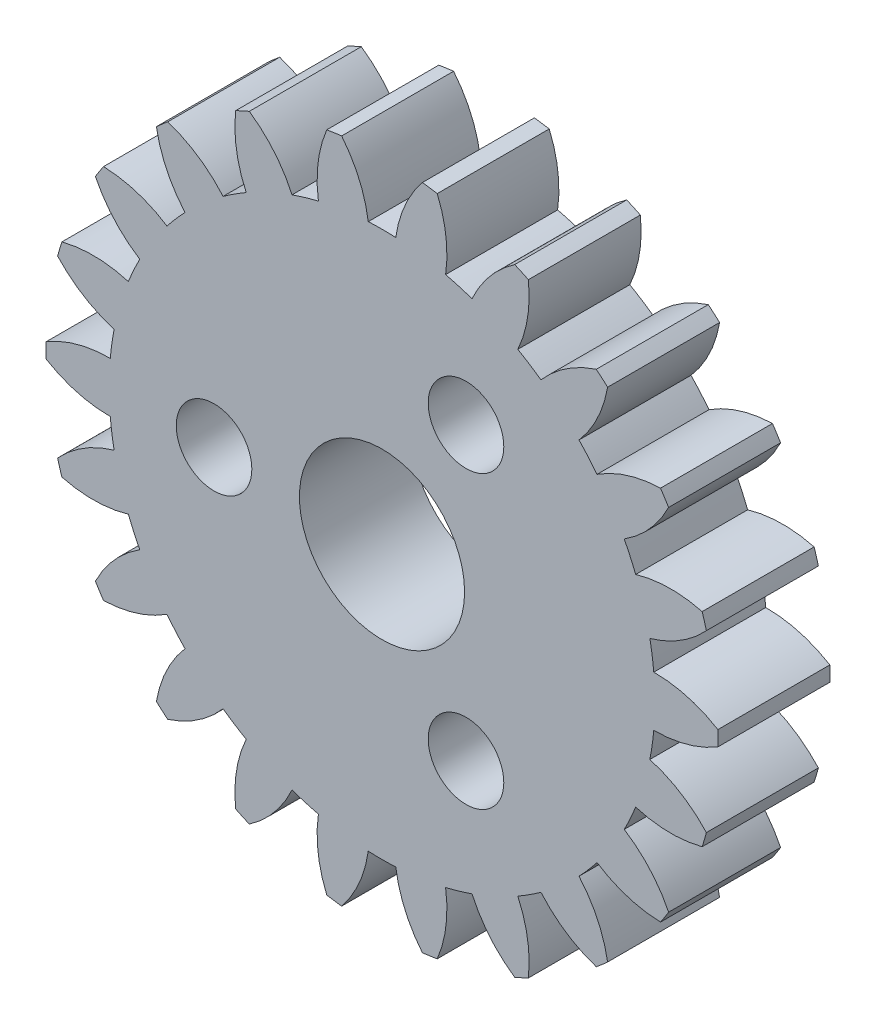
from build123d import *

# Parameters (mm, degrees)
MODEL_R             = 2.5
BOSS_EXTRUDE1_DEPTH = 4
SKETCH2_R           = 2.95
CUT_EXTRUDE1_DEPTH  = 4
SKETCH3_R           = 1.35
CUT_EXTRUDE2_DEPTH  = 4
CIRPATTERN1_COUNT   = 3


with BuildPart() as part:
    # Model → Boss-Extrude1 (new body)
    with BuildSketch(Plane.XY):
        with BuildLine():
            ThreePointArc((-11.997000624, 0.268283487), (-12, 0), (-11.997000624, -0.268283487))
            ThreePointArc((-11.997000624, -0.268283487), (-10.895606779, -0.741380557), (-9.707399683, -0.89966238))
            ThreePointArc((-9.707399683, -0.89966238), (-9.649769237, -1.387427358), (-9.56764597, -1.8716708))
            ThreePointArc((-9.56764597, -1.8716708), (-10.663129188, -2.358297721), (-11.586621996, -3.122529539))
            ThreePointArc((-11.586621996, -3.122529539), (-11.513915683, -3.380790682), (-11.43545361, -3.637361781))
            ThreePointArc((-11.43545361, -3.637361781), (-10.245387108, -3.780996591), (-9.060717605, -3.598110265))
            ThreePointArc((-9.060717605, -3.598110265), (-8.868002323, -4.049880962), (-8.652778483, -4.491372344))
            ThreePointArc((-8.652778483, -4.491372344), (-9.566788286, -5.266920743), (-10.237564162, -6.260373793))
            ThreePointArc((-10.237564162, -6.260373793), (-10.095042394, -6.487689809), (-9.947474154, -6.711762656))
            ThreePointArc((-9.947474154, -6.711762656), (-8.765147105, -6.514298768), (-7.679990073, -6.005060656))
            ThreePointArc((-7.679990073, -6.005060656), (-7.3678026, -6.384237295), (-7.036914342, -6.747209612))
            ThreePointArc((-7.036914342, -6.747209612), (-7.695403093, -7.74884917), (-8.059119765, -8.891039794))
            ThreePointArc((-8.059119765, -8.891039794), (-7.858328807, -9.068994892), (-7.653609502, -9.242416436))
            ThreePointArc((-7.653609502, -9.242416436), (-6.574807012, -8.719851201), (-5.67707542, -7.925516745))
            ThreePointArc((-5.67707542, -7.925516745), (-5.270707329, -8.201380692), (-4.850961252, -8.456428084))
            ThreePointArc((-4.850961252, -8.456428084), (-5.200582107, -9.603011921), (-5.227773414, -10.801406627))
            ThreePointArc((-5.227773414, -10.801406627), (-4.984980156, -10.915583944), (-4.739694926, -11.024304604))
            ThreePointArc((-4.739694926, -11.024304604), (-3.851815156, -10.218973149), (-3.214237879, -9.203894603))
            ThreePointArc((-3.214237879, -9.203894603), (-2.746610697, -9.354097), (-2.27201213, -9.480557045))
            ThreePointArc((-2.27201213, -9.480557045), (-2.284440889, -10.679195758), (-1.972903952, -11.836707735))
            ThreePointArc((-1.972903952, -11.836707735), (-1.707778059, -11.877857303), (-1.441798455, -11.913069177))
            ThreePointArc((-1.441798455, -11.913069177), (-0.816772145, -10.890214666), (-0.491001901, -9.736627657))
            ThreePointArc((-0.491001901, -9.736627657), (0, -9.749), (0.491001901, -9.736627657))
            ThreePointArc((0.491001901, -9.736627657), (0.816772145, -10.890214666), (1.441798455, -11.913069177))
            ThreePointArc((1.441798455, -11.913069177), (1.707778059, -11.877857303), (1.972903952, -11.836707735))
            ThreePointArc((1.972903952, -11.836707735), (2.284440889, -10.679195758), (2.27201213, -9.480557045))
            ThreePointArc((2.27201213, -9.480557045), (2.746610697, -9.354097), (3.214237879, -9.203894603))
            ThreePointArc((3.214237879, -9.203894603), (3.851815156, -10.218973149), (4.739694926, -11.024304604))
            ThreePointArc((4.739694926, -11.024304604), (4.984980156, -10.915583944), (5.227773414, -10.801406627))
            ThreePointArc((5.227773414, -10.801406627), (5.200582107, -9.603011921), (4.850961252, -8.456428084))
            ThreePointArc((4.850961252, -8.456428084), (5.270707329, -8.201380692), (5.67707542, -7.925516745))
            ThreePointArc((5.67707542, -7.925516745), (6.574807012, -8.719851201), (7.653609502, -9.242416436))
            ThreePointArc((7.653609502, -9.242416436), (7.858328807, -9.068994892), (8.059119765, -8.891039794))
            ThreePointArc((8.059119765, -8.891039794), (7.695403093, -7.74884917), (7.036914342, -6.747209612))
            ThreePointArc((7.036914342, -6.747209612), (7.3678026, -6.384237295), (7.679990073, -6.005060656))
            ThreePointArc((7.679990073, -6.005060656), (8.765147105, -6.514298768), (9.947474154, -6.711762656))
            ThreePointArc((9.947474154, -6.711762656), (10.095042394, -6.487689809), (10.237564162, -6.260373793))
            ThreePointArc((10.237564162, -6.260373793), (9.566788286, -5.266920743), (8.652778482, -4.491372344))
            ThreePointArc((8.652778482, -4.491372344), (8.868002323, -4.049880962), (9.060717605, -3.598110265))
            ThreePointArc((9.060717605, -3.598110265), (10.245387108, -3.780996591), (11.43545361, -3.637361781))
            ThreePointArc((11.43545361, -3.637361781), (11.513915683, -3.380790682), (11.586621996, -3.122529539))
            ThreePointArc((11.586621996, -3.122529539), (10.663129188, -2.358297721), (9.56764597, -1.8716708))
            ThreePointArc((9.56764597, -1.8716708), (9.649769237, -1.387427358), (9.707399683, -0.89966238))
            ThreePointArc((9.707399683, -0.89966238), (10.895606779, -0.741380557), (11.997000624, -0.268283487))
            ThreePointArc((11.997000624, -0.268283487), (12, 0), (11.997000624, 0.268283487))
            ThreePointArc((11.997000624, 0.268283487), (10.895606779, 0.741380557), (9.707399683, 0.89966238))
            ThreePointArc((9.707399683, 0.89966238), (9.649769237, 1.387427358), (9.56764597, 1.8716708))
            ThreePointArc((9.56764597, 1.8716708), (10.663129188, 2.358297721), (11.586621996, 3.122529539))
            ThreePointArc((11.586621996, 3.122529539), (11.513915683, 3.380790682), (11.43545361, 3.637361781))
            ThreePointArc((11.43545361, 3.637361781), (10.245387108, 3.780996591), (9.060717605, 3.598110265))
            ThreePointArc((9.060717605, 3.598110265), (8.868002323, 4.049880962), (8.652778483, 4.491372344))
            ThreePointArc((8.652778483, 4.491372344), (9.566788286, 5.266920743), (10.237564162, 6.260373793))
            ThreePointArc((10.237564162, 6.260373793), (10.095042394, 6.487689809), (9.947474154, 6.711762656))
            ThreePointArc((9.947474154, 6.711762656), (8.765147105, 6.514298768), (7.679990073, 6.005060656))
            ThreePointArc((7.679990073, 6.005060656), (7.3678026, 6.384237295), (7.036914342, 6.747209612))
            ThreePointArc((7.036914342, 6.747209612), (7.695403093, 7.74884917), (8.059119765, 8.891039794))
            ThreePointArc((8.059119765, 8.891039794), (7.858328807, 9.068994892), (7.653609502, 9.242416436))
            ThreePointArc((7.653609502, 9.242416436), (6.574807012, 8.719851201), (5.67707542, 7.925516745))
            ThreePointArc((5.67707542, 7.925516745), (5.270707329, 8.201380692), (4.850961252, 8.456428084))
            ThreePointArc((4.850961252, 8.456428084), (5.200582107, 9.603011921), (5.227773414, 10.801406627))
            ThreePointArc((5.227773414, 10.801406627), (4.984980156, 10.915583944), (4.739694926, 11.024304604))
            ThreePointArc((4.739694926, 11.024304604), (3.851815156, 10.218973149), (3.214237879, 9.203894603))
            ThreePointArc((3.214237879, 9.203894603), (2.746610697, 9.354097), (2.27201213, 9.480557045))
            ThreePointArc((2.27201213, 9.480557045), (2.284440889, 10.679195758), (1.972903952, 11.836707735))
            ThreePointArc((1.972903952, 11.836707735), (1.707778059, 11.877857303), (1.441798455, 11.913069177))
            ThreePointArc((1.441798455, 11.913069177), (0.816772145, 10.890214666), (0.491001901, 9.736627657))
            ThreePointArc((0.491001901, 9.736627657), (0, 9.749), (-0.491001901, 9.736627657))
            ThreePointArc((-0.491001901, 9.736627657), (-0.816772145, 10.890214666), (-1.441798455, 11.913069177))
            ThreePointArc((-1.441798455, 11.913069177), (-1.707778059, 11.877857303), (-1.972903952, 11.836707735))
            ThreePointArc((-1.972903952, 11.836707735), (-2.284440889, 10.679195758), (-2.27201213, 9.480557045))
            ThreePointArc((-2.27201213, 9.480557045), (-2.746610697, 9.354097), (-3.214237879, 9.203894603))
            ThreePointArc((-3.214237879, 9.203894603), (-3.851815156, 10.218973149), (-4.739694926, 11.024304604))
            ThreePointArc((-4.739694926, 11.024304604), (-4.984980156, 10.915583944), (-5.227773414, 10.801406627))
            ThreePointArc((-5.227773414, 10.801406627), (-5.200582107, 9.603011921), (-4.850961252, 8.456428084))
            ThreePointArc((-4.850961252, 8.456428084), (-5.270707329, 8.201380692), (-5.67707542, 7.925516745))
            ThreePointArc((-5.67707542, 7.925516745), (-6.574807012, 8.719851201), (-7.653609502, 9.242416436))
            ThreePointArc((-7.653609502, 9.242416436), (-7.858328807, 9.068994892), (-8.059119765, 8.891039794))
            ThreePointArc((-8.059119765, 8.891039794), (-7.695403093, 7.74884917), (-7.036914342, 6.747209612))
            ThreePointArc((-7.036914342, 6.747209612), (-7.3678026, 6.384237295), (-7.679990073, 6.005060656))
            ThreePointArc((-7.679990073, 6.005060656), (-8.765147105, 6.514298768), (-9.947474154, 6.711762656))
            ThreePointArc((-9.947474154, 6.711762656), (-10.095042394, 6.487689809), (-10.237564162, 6.260373793))
            ThreePointArc((-10.237564162, 6.260373793), (-9.566788286, 5.266920743), (-8.652778482, 4.491372344))
            ThreePointArc((-8.652778482, 4.491372344), (-8.868002323, 4.049880962), (-9.060717605, 3.598110265))
            ThreePointArc((-9.060717605, 3.598110265), (-10.245387108, 3.780996591), (-11.43545361, 3.637361781))
            ThreePointArc((-11.43545361, 3.637361781), (-11.513915683, 3.380790682), (-11.586621996, 3.122529539))
            ThreePointArc((-11.586621996, 3.122529539), (-10.663129188, 2.358297721), (-9.56764597, 1.8716708))
            ThreePointArc((-9.56764597, 1.8716708), (-9.649769237, 1.387427358), (-9.707399683, 0.89966238))
            ThreePointArc((-9.707399683, 0.89966238), (-10.895606779, 0.741380557), (-11.997000624, 0.268283487))
        make_face()
        Circle(MODEL_R, mode=Mode.SUBTRACT)
    extrude(amount=BOSS_EXTRUDE1_DEPTH)

    # Sketch2 → Cut-Extrude1 (cut)
    with BuildSketch(Plane.XY.offset(4)):
        Circle(SKETCH2_R)
    extrude(amount=-CUT_EXTRUDE1_DEPTH, mode=Mode.SUBTRACT)

    # Sketch3 → Cut-Extrude2 (cut)
    with BuildSketch(Plane.XY.offset(4)):
        with Locations((-6, 0)):
            Circle(SKETCH3_R)
    cut_extrude2 = extrude(amount=-CUT_EXTRUDE2_DEPTH, mode=Mode.SUBTRACT)

    # CirPattern1: Cut-Extrude2 ×3 about axis
    cirpattern1_axis = Axis((0, 0, 0), (0, 0, 1))
    for i in range(1, CIRPATTERN1_COUNT):
        add(cut_extrude2.rotate(cirpattern1_axis, i * 360 / CIRPATTERN1_COUNT), mode=Mode.SUBTRACT)


solid = part.part
